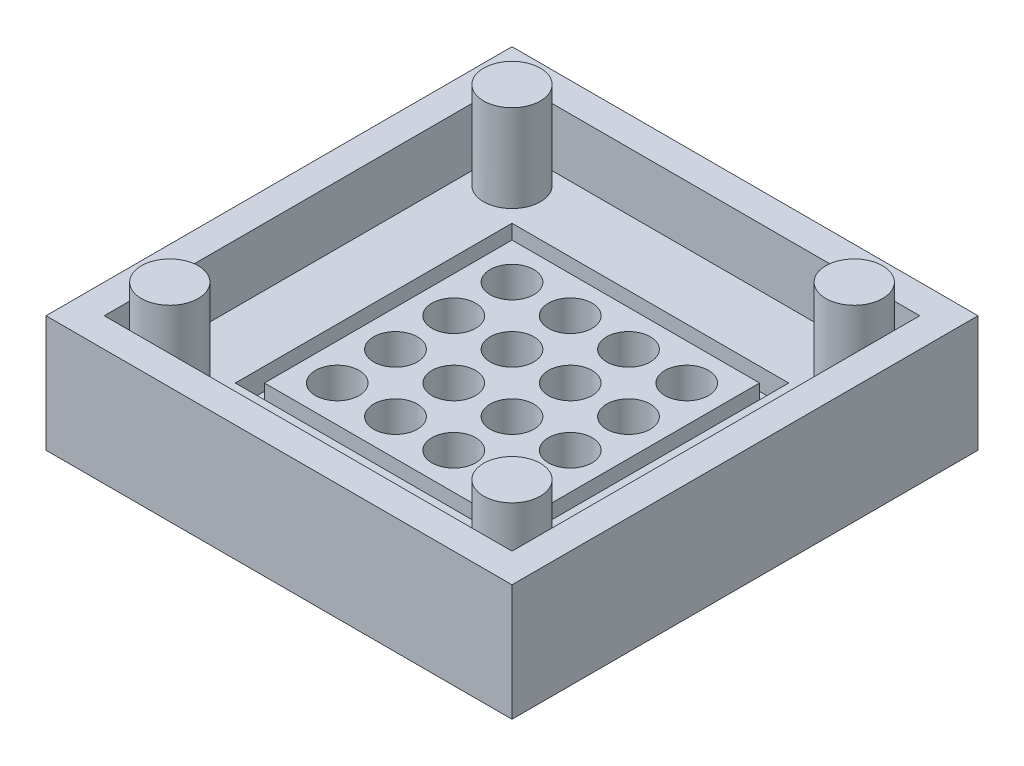
from build123d import *

# Parameters (mm, degrees)
SKETCH1_W           = 32
SKETCH1_H           = 32
BOSS_EXTRUDE1_DEPTH = 8
SKETCH2_W           = 28
SKETCH2_H           = 28
CUT_EXTRUDE1_DEPTH  = 4
SKETCH3_W           = 19
SKETCH3_H           = 19
CUT_EXTRUDE2_DEPTH  = 1.5
SKETCH4_W           = 17
SKETCH4_H           = 17
BOSS_EXTRUDE2_DEPTH = 1.5
SKETCH6_R           = 1.95
BOSS_EXTRUDE3_DEPTH = 6
SKETCH7_R           = 1.5
CUT_EXTRUDE3_DEPTH  = 3


with BuildPart() as part:
    # Sketch1 → Boss-Extrude1 (new body)
    with BuildSketch(Plane(origin=(0, 0, 0), x_dir=(1, 0, 0), z_dir=(0, 1, 0))):
        Rectangle(SKETCH1_W, SKETCH1_H)
    extrude(amount=BOSS_EXTRUDE1_DEPTH)

    # Sketch2 → Cut-Extrude1 (cut)
    with BuildSketch(Plane(origin=(0, 8, 0), x_dir=(1, 0, 0), z_dir=(0, 1, 0))):
        Rectangle(SKETCH2_W, SKETCH2_H)
    extrude(amount=-CUT_EXTRUDE1_DEPTH, mode=Mode.SUBTRACT)

    # Sketch3 → Cut-Extrude2 (cut)
    with BuildSketch(Plane(origin=(0, 4, 0), x_dir=(1, 0, 0), z_dir=(0, 1, 0))):
        Rectangle(SKETCH3_W, SKETCH3_H)
    extrude(amount=-CUT_EXTRUDE2_DEPTH, mode=Mode.SUBTRACT)

    # Sketch4 → Boss-Extrude2 (add)
    with BuildSketch(Plane(origin=(0, 2.5, 0), x_dir=(1, 0, 0), z_dir=(0, 1, 0))):
        Rectangle(SKETCH4_W, SKETCH4_H)
    extrude(amount=BOSS_EXTRUDE2_DEPTH)

    # Sketch6 → Boss-Extrude3 (add)
    with BuildSketch(Plane(origin=(0, 4, 0), x_dir=(1, 0, 0), z_dir=(0, 1, 0))):
        with Locations((-11.75, 11.75)):
            Circle(SKETCH6_R)
        with Locations((11.75, 11.75)):
            Circle(SKETCH6_R)
        with Locations((11.75, -11.75)):
            Circle(SKETCH6_R)
        with Locations((-11.75, -11.75)):
            Circle(SKETCH6_R)
    extrude(amount=BOSS_EXTRUDE3_DEPTH)

    # Sketch7 → Cut-Extrude3 (cut)
    with BuildSketch(Plane(origin=(0, 4, 0), x_dir=(1, 0, 0), z_dir=(0, 1, 0))):
        with Locations((-6, -6)):
            Circle(SKETCH7_R)
        with Locations((-2, -6)):
            Circle(SKETCH7_R)
        with Locations((2, -6)):
            Circle(SKETCH7_R)
        with Locations((6, -6)):
            Circle(SKETCH7_R)
        with Locations((-2, -2)):
            Circle(SKETCH7_R)
        with Locations((2, -2)):
            Circle(SKETCH7_R)
        with Locations((6, -2)):
            Circle(SKETCH7_R)
        with Locations((-2, 2)):
            Circle(SKETCH7_R)
        with Locations((2, 2)):
            Circle(SKETCH7_R)
        with Locations((6, 2)):
            Circle(SKETCH7_R)
        with Locations((-2, 6)):
            Circle(SKETCH7_R)
        with Locations((2, 6)):
            Circle(SKETCH7_R)
        with Locations((6, 6)):
            Circle(SKETCH7_R)
        with Locations((-6, -2)):
            Circle(SKETCH7_R)
        with Locations((-6, 2)):
            Circle(SKETCH7_R)
        with Locations((-6, 6)):
            Circle(SKETCH7_R)
    extrude(amount=-CUT_EXTRUDE3_DEPTH, mode=Mode.SUBTRACT)


solid = part.part
